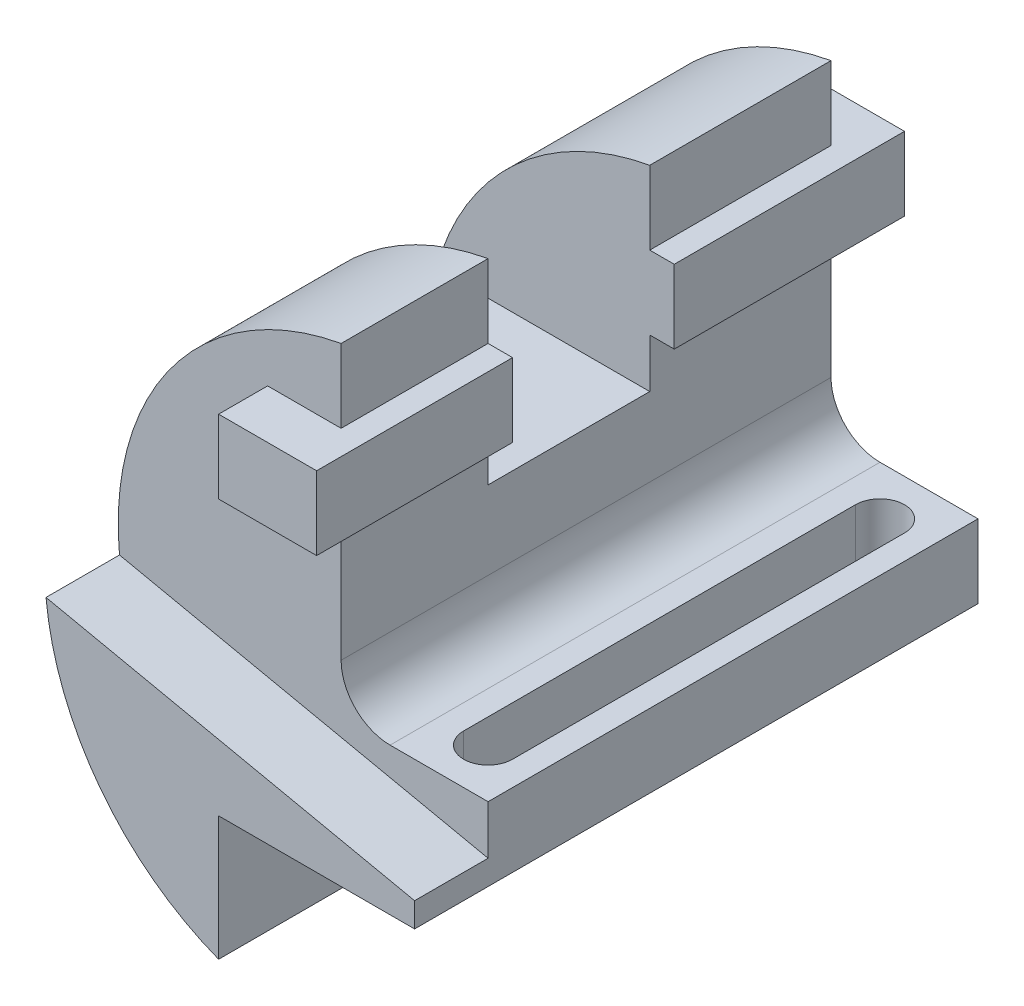
from build123d import *

# Parameters (mm, degrees)
BOSS_EXTRUDE1_DEPTH      = 115
CUT_EXTRUDE1_DEPTH       = 1
CUT_EXTRUDE1_DEPTH_BACK  = 15
SKETCH3_W                = 20
SKETCH3_H                = 15
BOSS_EXTRUDE2_DEPTH      = 10
BOSS_EXTRUDE2_DEPTH_BACK = 110
SKETCH4_W                = 33
SKETCH4_H                = 40
CUT_EXTRUDE2_DEPTH       = 31
CUT_EXTRUDE2_DEPTH_BACK  = 46.5
CUT_EXTRUDE4_DEPTH       = 67
CUT_EXTRUDE4_DEPTH_BACK  = 41.362796982
FILLET1_R                = 10


with BuildPart() as part:
    # Sketch1 → Boss-Extrude1 (new body)
    with BuildSketch(Plane.XY):
        with BuildLine():
            Line((0, 0), (40, 0))
            Line((40, 0), (40, 15))
            Line((40, 15), (10, 15))
            Line((10, 15), (10, 81))
            ThreePointArc((10, 81), (-35.256322222, 31.603413808), (0, -25.362796982))
            Line((0, -25.362796982), (0, 0))
        make_face()
    extrude(amount=BOSS_EXTRUDE1_DEPTH)

    # Sketch2 → Cut-Extrude1 (cut, two sides)
    with BuildSketch(Plane.XY.offset(115)) as cut_extrude1_sk:
        with BuildLine():
            Line((40, 5), (-35.235044142, 20.9917023))
            ThreePointArc((-35.235044142, 20.9917023), (-24.318751046, 59.816391467), (10, 81))
            Line((10, 81), (10, 15))
            Line((10, 15), (40, 15))
            Line((40, 15), (40, 5))
        make_face()
    extrude(amount=CUT_EXTRUDE1_DEPTH, mode=Mode.SUBTRACT)
    extrude(cut_extrude1_sk.sketch, amount=-CUT_EXTRUDE1_DEPTH_BACK, mode=Mode.SUBTRACT)

    # Sketch3 → Boss-Extrude2 (add, two sides)
    with BuildSketch(Plane(origin=(0, 0, 0), x_dir=(-1, 0, 0), z_dir=(0, 0, -1))) as boss_extrude2_sk:
        with Locations((-5, 58.5)):
            Rectangle(SKETCH3_W, SKETCH3_H)
    extrude(amount=BOSS_EXTRUDE2_DEPTH)
    extrude(boss_extrude2_sk.sketch, amount=-BOSS_EXTRUDE2_DEPTH_BACK)

    # Sketch4 → Cut-Extrude2 (cut, two sides)
    with BuildSketch(Plane(origin=(10, 0, 0), x_dir=(0, 0, -1), z_dir=(1, 0, 0))) as cut_extrude2_sk:
        with Locations((-53.5, 61)):
            Rectangle(SKETCH4_W, SKETCH4_H)
    extrude(amount=CUT_EXTRUDE2_DEPTH, mode=Mode.SUBTRACT)
    extrude(cut_extrude2_sk.sketch, amount=-CUT_EXTRUDE2_DEPTH_BACK, mode=Mode.SUBTRACT)

    # Sketch6 → Cut-Extrude4 (cut, two sides)
    with BuildSketch(Plane(origin=(0, 15, 0), x_dir=(1, 0, 0), z_dir=(0, 1, 0))) as cut_extrude4_sk:
        with BuildLine():
            Line((35, -10), (35, -90))
            ThreePointArc((35, -90), (30, -95), (25, -90))
            Line((25, -90), (25, -10))
            ThreePointArc((25, -10), (30, -5), (35, -10))
        make_face()
    extrude(amount=CUT_EXTRUDE4_DEPTH, mode=Mode.SUBTRACT)
    extrude(cut_extrude4_sk.sketch, amount=-CUT_EXTRUDE4_DEPTH_BACK, mode=Mode.SUBTRACT)

    # Fillet1
    fillet1_edges = [part.edges().sort_by_distance(p)[0] for p in [
        (10, 15, 50),
    ]]
    fillet(fillet1_edges, radius=FILLET1_R)


solid = part.part
